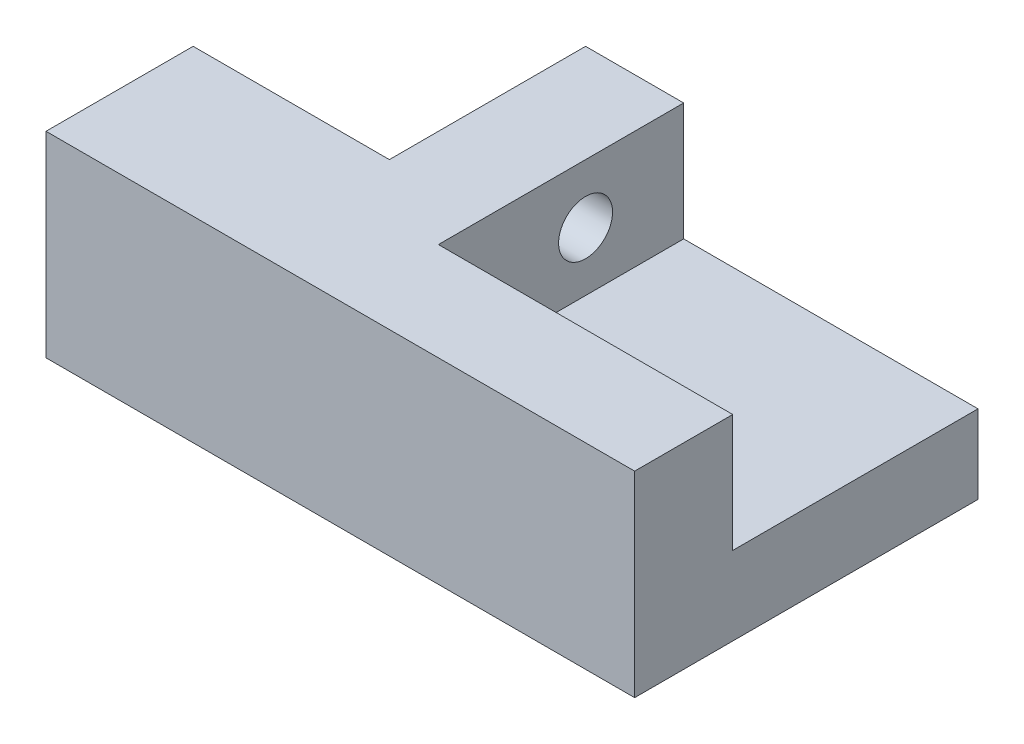
from build123d import *

# Parameters (mm, degrees)
BOSS_EXTRUDE1_DEPTH = 20
SKETCH2_W           = 30
SKETCH2_H           = 25
CUT_EXTRUDE1_DEPTH  = 12
SKETCH5_R           = 2.75
CUT_EXTRUDE4_DEPTH  = 31
SKETCH6_R           = 6.7
CUT_EXTRUDE5_DEPTH  = 5
SKETCH7_R           = 2.5
CUT_EXTRUDE6_DEPTH  = 16


with BuildPart() as part:
    # Sketch1 → Boss-Extrude1 (new body)
    with BuildSketch(Plane(origin=(0, 0, 0), x_dir=(1, 0, 0), z_dir=(0, 1, 0))):
        Polygon((0, 0), (60, 0), (60, 35), (20, 35), (20, 15), (0, 15), align=None)
    extrude(amount=BOSS_EXTRUDE1_DEPTH)

    # Sketch2 → Cut-Extrude1 (cut)
    with BuildSketch(Plane(origin=(0, 20, 0), x_dir=(1, 0, 0), z_dir=(0, 1, 0))):
        with Locations((45, 22.5)):
            Rectangle(SKETCH2_W, SKETCH2_H)
    extrude(amount=-CUT_EXTRUDE1_DEPTH, mode=Mode.SUBTRACT)

    # Sketch5 → Cut-Extrude4 (cut, through all)
    with BuildSketch(Plane(origin=(30, 0, 0), x_dir=(0, 0, -1), z_dir=(1, 0, 0))):
        with Locations((25, 14)):
            Circle(SKETCH5_R)
    extrude(amount=-CUT_EXTRUDE4_DEPTH, mode=Mode.SUBTRACT)

    # Sketch6 → Cut-Extrude5 (cut)
    with BuildSketch(Plane.XZ):
        with Locations((46.1, -12.525762493)):
            Circle(SKETCH6_R)
    extrude(amount=-CUT_EXTRUDE5_DEPTH, mode=Mode.SUBTRACT)

    # Sketch7 → Cut-Extrude6 (cut, through all)
    with BuildSketch(Plane.XZ.offset(-5)):
        with Locations((46.1, -12.525762493)):
            Circle(SKETCH7_R)
    extrude(amount=-CUT_EXTRUDE6_DEPTH, mode=Mode.SUBTRACT)


solid = part.part
